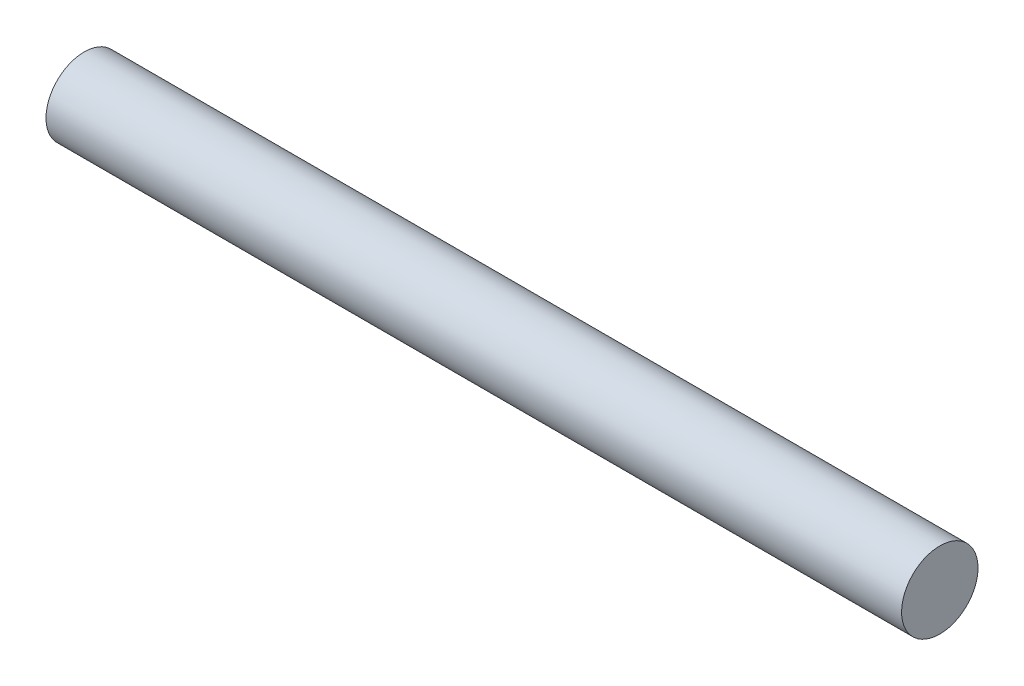
from build123d import *

# Parameters (mm, degrees)
SKETCH1_R                = 6.35
BOSS_EXTRUDE1_DEPTH      = 71.0875
BOSS_EXTRUDE1_DEPTH_BACK = 71.0875


with BuildPart() as part:
    # Sketch1 → Boss-Extrude1 (new body, two sides)
    with BuildSketch(Plane(origin=(0, 0, 0), x_dir=(0, 0, -1), z_dir=(1, 0, 0))) as boss_extrude1_sk:
        Circle(SKETCH1_R)
    extrude(amount=BOSS_EXTRUDE1_DEPTH)
    extrude(boss_extrude1_sk.sketch, amount=-BOSS_EXTRUDE1_DEPTH_BACK)


solid = part.part
